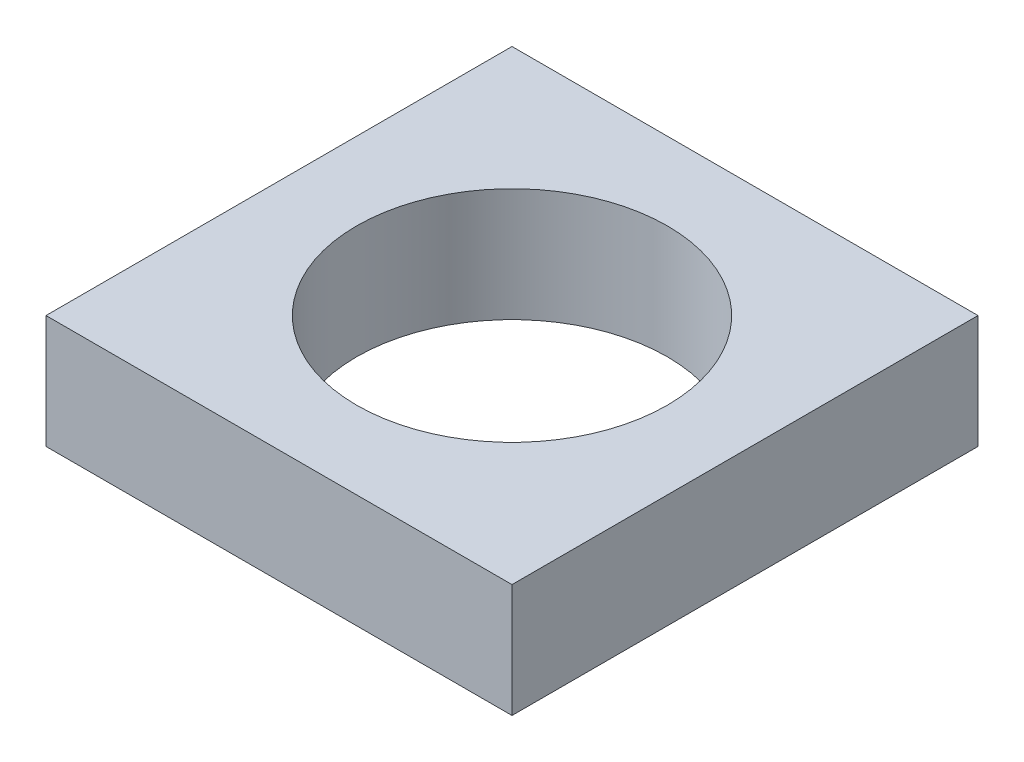
from build123d import *

# Parameters (mm, degrees)
SKETCH1_W           = 60
SKETCH1_H           = 60
SKETCH1_R           = 20
BOSS_EXTRUDE1_DEPTH = 14.6


with BuildPart() as part:
    # Sketch1 → Boss-Extrude1 (new body)
    with BuildSketch(Plane(origin=(0, 0, 0), x_dir=(1, 0, 0), z_dir=(0, 1, 0))):
        Rectangle(SKETCH1_W, SKETCH1_H)
        Circle(SKETCH1_R, mode=Mode.SUBTRACT)
    extrude(amount=BOSS_EXTRUDE1_DEPTH)


solid = part.part
